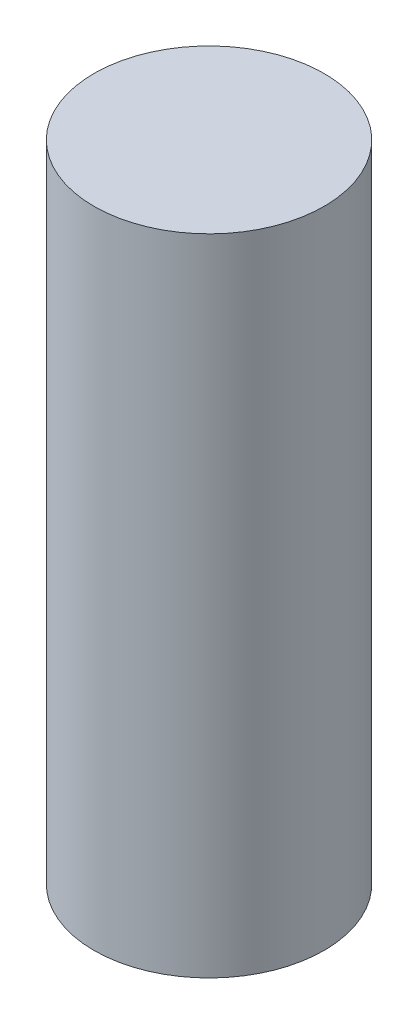
from build123d import *

# Parameters (mm, degrees)
SKETCH1_R           = 3.175
BOSS_EXTRUDE1_DEPTH = 17.78


with BuildPart() as part:
    # Sketch1 → Boss-Extrude1 (new body)
    with BuildSketch(Plane(origin=(0, 0, 0), x_dir=(1, 0, 0), z_dir=(0, 1, 0))):
        Circle(SKETCH1_R)
    extrude(amount=BOSS_EXTRUDE1_DEPTH)


solid = part.part
